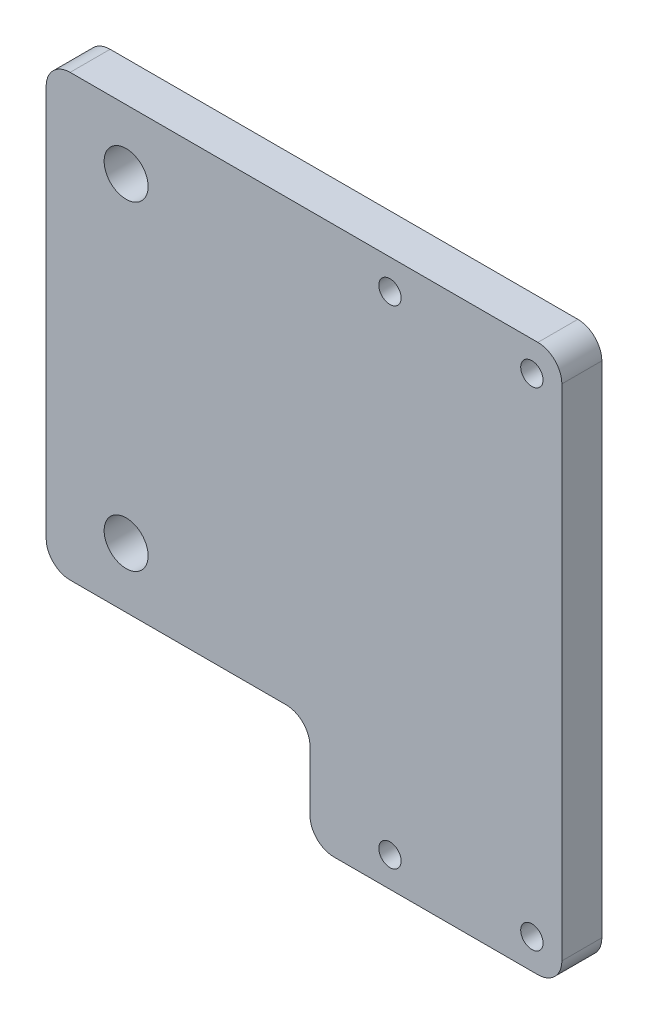
from build123d import *

# Parameters (mm, degrees)
MAIN_DEPTH            = 5
GEAR_AXIS_HOLES_D     = 5.5
FILLET1_R             = 3
F_3_CLEARANCE_HOLE1_D = 2.794


with BuildPart() as part:
    # Base → Main (new body)
    with BuildSketch(Plane.XY):
        Polygon((0, 27.5), (-33, 27.5), (-33, -27.5), (0, -27.5), (0, -40.995), (24, -40.995), (31.5, -40.995), (31.5, 27.5), (24, 27.5), align=None)
    extrude(amount=MAIN_DEPTH)

    # Gear Axis Holes (through all)
    with Locations(Plane(origin=(0, 0, 0), x_dir=(-1, 0, 0), z_dir=(0, 0, -1))):
        with Locations((23, -20), (23, 20)):
            Hole(GEAR_AXIS_HOLES_D / 2)

    # Fillet1
    fillet1_edges = [part.edges().sort_by_distance(p)[0] for p in [
        (31.5, 27.5, 2.5),
        (31.5, -40.995, 2.5),
        (0, -40.995, 2.5),
        (0, -27.5, 2.5),
        (-33, -27.5, 2.5),
        (-33, 27.5, 2.5),
    ]]
    fillet(fillet1_edges, radius=FILLET1_R)

    # #3 Clearance Hole1 (through all)
    with Locations(Plane.XY.offset(5)):
        with Locations((10, 23.75), (27.75, 23.75), (27.75, -37.245), (10, -37.245)):
            Hole(F_3_CLEARANCE_HOLE1_D / 2)


solid = part.part
